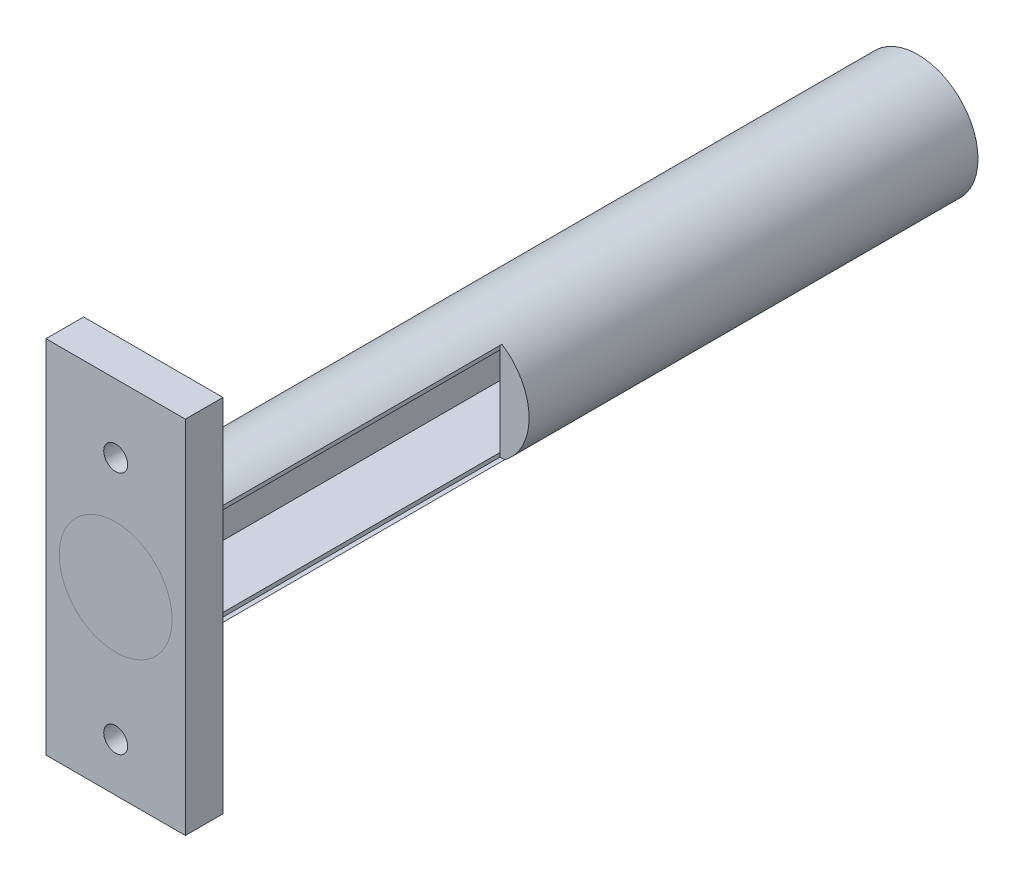
from build123d import *

# Parameters (mm, degrees)
SKETCH1_R           = 8
BOSS_EXTRUDE1_DEPTH = 101.6
SKETCH2_W           = 18.519646932
SKETCH2_H           = 47.927417474
BOSS_EXTRUDE2_DEPTH = 5
SKETCH3_R           = 7.5
BOSS_EXTRUDE3_DEPTH = 0.0001
SKETCH4_R           = 1.59
CUT_EXTRUDE1_DEPTH  = 34
SKETCH7_R           = 3.185
CUT_EXTRUDE2_DEPTH  = 4
SKETCH8_W           = 8.28003219
SKETCH8_H           = 11.80237286
CUT_EXTRUDE7_DEPTH  = 96
SKETCH12_W          = 40.69032966
SKETCH12_H          = 13.123197876
CUT_EXTRUDE8_DEPTH  = 35
SKETCH13_W          = 2.556138798
SKETCH13_H          = 10.974311436
CUT_EXTRUDE9_DEPTH  = 35


with BuildPart() as part:
    # Sketch1 → Boss-Extrude1 (new body)
    with BuildSketch(Plane.XY):
        Circle(SKETCH1_R)
    extrude(amount=BOSS_EXTRUDE1_DEPTH)

    # Sketch2 → Boss-Extrude2 (add)
    with BuildSketch(Plane.XY.offset(101.6)):
        Rectangle(SKETCH2_W, SKETCH2_H)
    extrude(amount=BOSS_EXTRUDE2_DEPTH)

    # Sketch3 → Boss-Extrude3 (add)
    with BuildSketch(Plane.XY.offset(106.6)):
        Circle(SKETCH3_R)
    extrude(amount=BOSS_EXTRUDE3_DEPTH)

    # Sketch4 → Cut-Extrude1 (cut)
    with BuildSketch(Plane(origin=(0, 0, 101.6), x_dir=(-1, 0, 0), z_dir=(0, 0, -1))):
        with Locations((0, 14.883091948)):
            Circle(SKETCH4_R)
        with Locations((0, -17.523878239)):
            Circle(SKETCH4_R)
    extrude(amount=-CUT_EXTRUDE1_DEPTH, mode=Mode.SUBTRACT)

    # Sketch7 → Cut-Extrude2 (cut)
    with BuildSketch(Plane(origin=(0, 0, 0), x_dir=(-1, 0, 0), z_dir=(0, 0, -1))):
        Circle(SKETCH7_R)
    extrude(amount=-CUT_EXTRUDE2_DEPTH, mode=Mode.SUBTRACT)

    # Sketch8 → Cut-Extrude7 (cut)
    with BuildSketch(Plane(origin=(0, 0, 4), x_dir=(-1, 0, 0), z_dir=(0, 0, -1))):
        Rectangle(SKETCH8_W, SKETCH8_H)
    extrude(amount=-CUT_EXTRUDE7_DEPTH, mode=Mode.SUBTRACT)

    # Sketch12 → Cut-Extrude8 (cut)
    with BuildSketch(Plane.ZY.offset(-4.140016095)):
        with Locations((80.002136868, 0.118820051)):
            Rectangle(SKETCH12_W, SKETCH12_H)
    extrude(amount=-CUT_EXTRUDE8_DEPTH, mode=Mode.SUBTRACT)

    # Sketch13 → Cut-Extrude9 (cut)
    with BuildSketch(Plane(origin=(-4.140016095, 0, 0), x_dir=(0, 0, -1), z_dir=(1, 0, 0))):
        with Locations((-97.09530972, 0)):
            Rectangle(SKETCH13_W, SKETCH13_H)
    extrude(amount=-CUT_EXTRUDE9_DEPTH, mode=Mode.SUBTRACT)


solid = part.part
